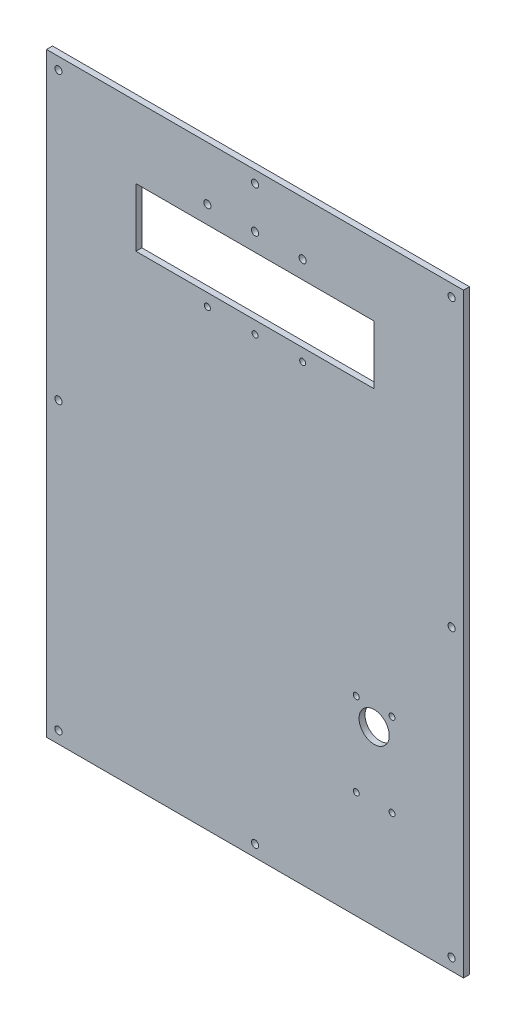
from build123d import *

# Parameters (mm, degrees)
SKETCH1_W           = 350
SKETCH1_H           = 500
SKETCH1_R           = 3
SKETCH1_R_2         = 2.5
SKETCH1_R_3         = 12.665
SKETCH1_W_2         = 200
SKETCH1_H_2         = 49.2
BOSS_EXTRUDE1_DEPTH = 5


with BuildPart() as part:
    # Sketch1 → Boss-Extrude1 (new body)
    with BuildSketch(Plane.XY):
        Rectangle(SKETCH1_W, SKETCH1_H)
        with Locations((-165, 0)):
            Circle(SKETCH1_R, mode=Mode.SUBTRACT)
        with Locations((165, -240)):
            Circle(SKETCH1_R, mode=Mode.SUBTRACT)
        with Locations((165, 0)):
            Circle(SKETCH1_R, mode=Mode.SUBTRACT)
        with Locations((165, 240)):
            Circle(SKETCH1_R, mode=Mode.SUBTRACT)
        with Locations((0, 240)):
            Circle(SKETCH1_R, mode=Mode.SUBTRACT)
        with Locations((0, -240)):
            Circle(SKETCH1_R, mode=Mode.SUBTRACT)
        with Locations((-165, 240)):
            Circle(SKETCH1_R, mode=Mode.SUBTRACT)
        with Locations((-165, -240)):
            Circle(SKETCH1_R, mode=Mode.SUBTRACT)
        with Locations((40, 205)):
            Circle(SKETCH1_R, mode=Mode.SUBTRACT)
        with Locations((0, 205)):
            Circle(SKETCH1_R, mode=Mode.SUBTRACT)
        with Locations((-40, 205)):
            Circle(SKETCH1_R, mode=Mode.SUBTRACT)
        with Locations((0, 130.4)):
            Circle(SKETCH1_R_2, mode=Mode.SUBTRACT)
        with Locations((40, 130.4)):
            Circle(SKETCH1_R_2, mode=Mode.SUBTRACT)
        with Locations((-40, 130.4)):
            Circle(SKETCH1_R_2, mode=Mode.SUBTRACT)
        with Locations((115, -90)):
            Circle(SKETCH1_R_2, mode=Mode.SUBTRACT)
        with Locations((85, -90)):
            Circle(SKETCH1_R_2, mode=Mode.SUBTRACT)
        with Locations((115, -160)):
            Circle(SKETCH1_R_2, mode=Mode.SUBTRACT)
        with Locations((85, -160)):
            Circle(SKETCH1_R_2, mode=Mode.SUBTRACT)
        with Locations((100, -105)):
            Circle(SKETCH1_R_3, mode=Mode.SUBTRACT)
        with Locations((0, 165.4)):
            Rectangle(SKETCH1_W_2, SKETCH1_H_2, mode=Mode.SUBTRACT)
    extrude(amount=BOSS_EXTRUDE1_DEPTH)


solid = part.part
